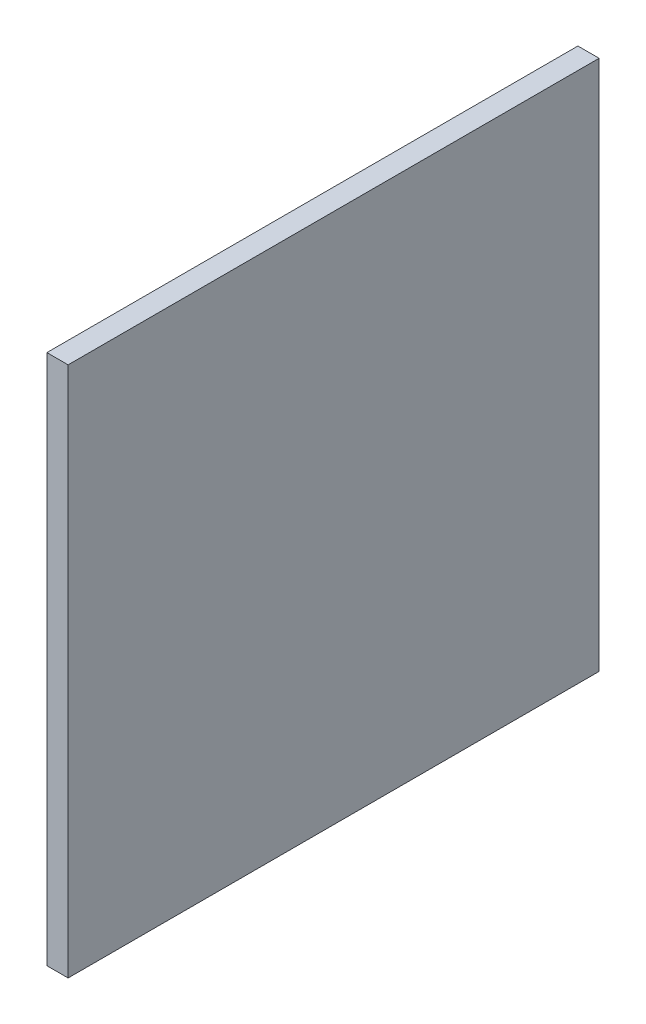
from build123d import *

# Parameters (mm, degrees)
SKETCH_1_W      = 500
SKETCH_1_H      = 500
EXTRUDE_1_DEPTH = 20


with BuildPart() as part:
    # 草图1 → 凸台-拉伸1 (new body)
    with BuildSketch(Plane(origin=(0, 0, 0), x_dir=(0, 0, -1), z_dir=(1, 0, 0))):
        Rectangle(SKETCH_1_W, SKETCH_1_H)
    extrude(amount=EXTRUDE_1_DEPTH)


solid = part.part
